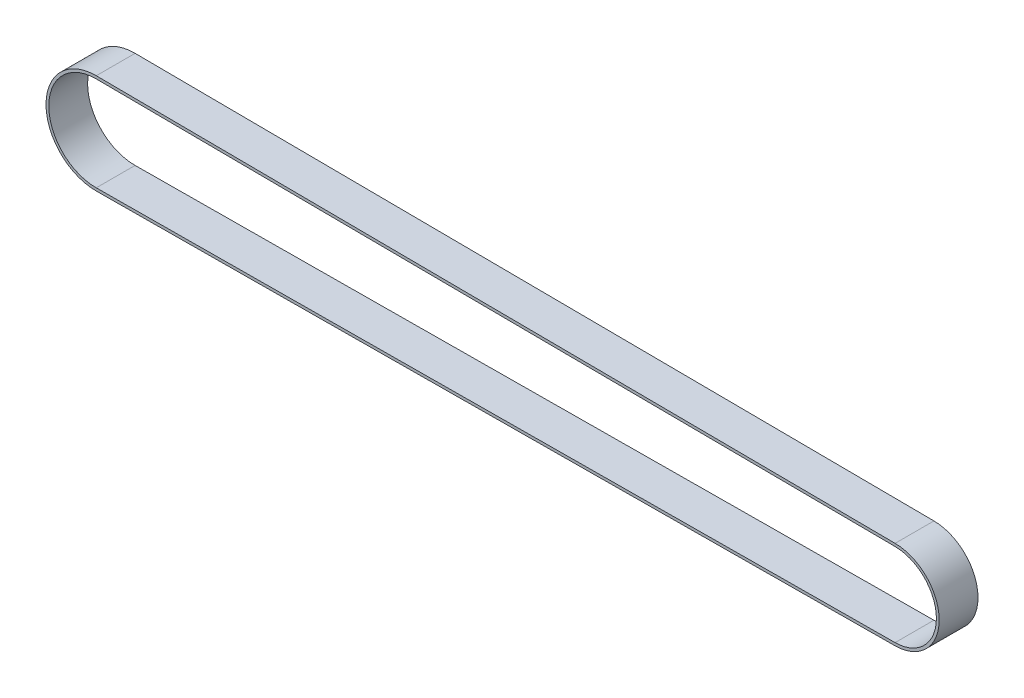
from build123d import *

# Parameters (mm, degrees)
EXTRUDE_THIN1_DEPTH = 7


with BuildPart() as part:
    # Sketch2 → Extrude-Thin1 (new body)
    with BuildSketch(Plane.XY):
        with BuildLine():
            Line((3.0625, 9.499782983), (147.055555556, 8.499807096))
            ThreePointArc((147.055555556, 8.499807096), (155, 0.5), (147.055555556, -7.499807096))
            Line((147.055555556, -7.499807096), (3.0625, -8.499782983))
            ThreePointArc((3.0625, -8.499782983), (-6, 0.5), (3.0625, 9.499782983))
        make_face()
        with BuildLine():
            Line((3.059027778, 8.99979504), (147.052083333, 7.999819153))
            ThreePointArc((147.052083333, 7.999819153), (154.5, 0.5), (147.052083333, -6.999819153))
            Line((147.052083333, -6.999819153), (3.059027778, -7.99979504))
            ThreePointArc((3.059027778, -7.99979504), (-5.5, 0.5), (3.059027778, 8.99979504))
        make_face(mode=Mode.SUBTRACT)
    extrude(amount=-EXTRUDE_THIN1_DEPTH)


solid = part.part
